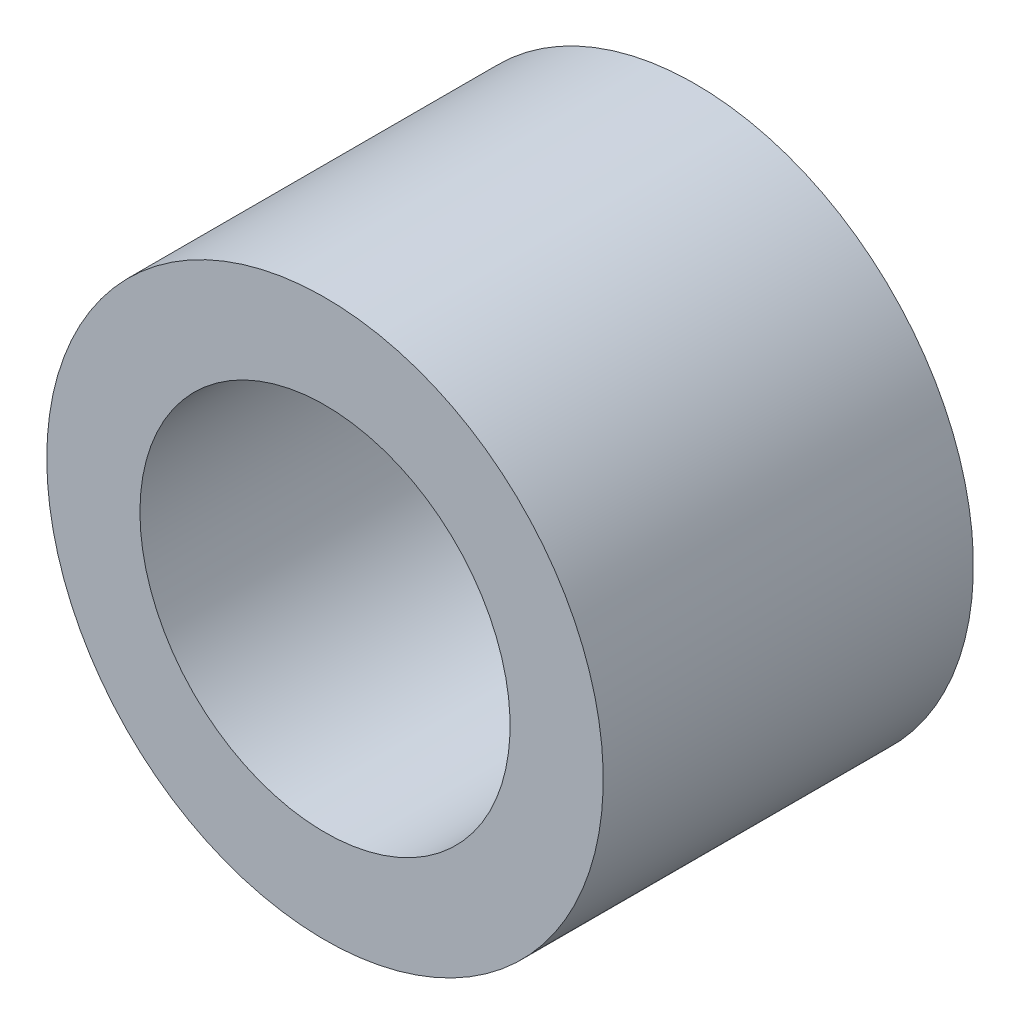
from build123d import *

# Parameters (mm, degrees)
SKETCH1_W = 1.51
SKETCH1_H = 6


with BuildPart() as part:
    # Sketch1 → Revolve1 (revolve)
    with BuildSketch(Plane.XZ):
        with Locations((3.755, 0)):
            Rectangle(SKETCH1_W, SKETCH1_H)
    revolve(axis=Axis((0, 0, 3), (0, 0, -1)))


solid = part.part
